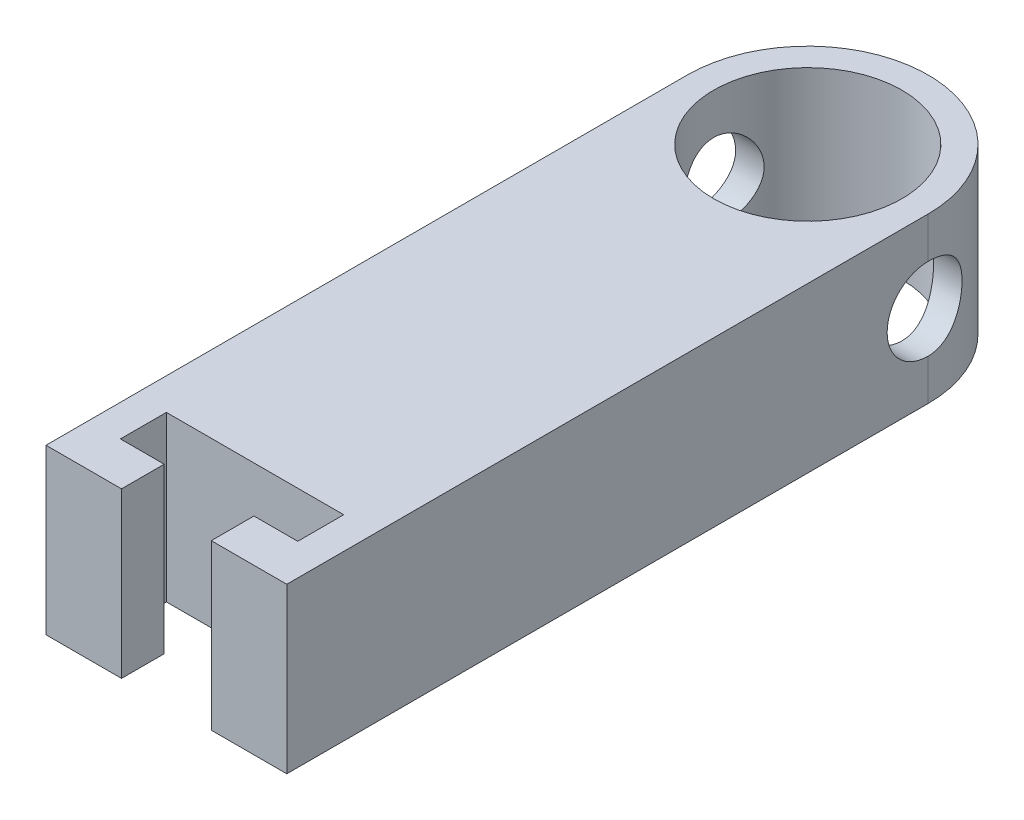
from build123d import *

# Parameters (mm, degrees)
SKETCH2_W               = 20.32
SKETCH2_H               = 7.62
SKETCH2_R               = 1.905
BOSS_EXTRUDE1_DEPTH     = 12.7
BOSS_EXTRUDE1_2_DEPTH   = 12.7
SKETCH4_W               = 7.62
SKETCH4_H               = 55.88
BOSS_EXTRUDE2_DEPTH     = 28.702
SKETCH5_W               = 27.94
SKETCH5_H               = 55.88
BOSS_EXTRUDE3_DEPTH     = 7.62
SKETCH6_R               = 10.922
BOSS_EXTRUDE6_DEPTH     = 55.88
SKETCH7_R               = 4.7625
CUT_EXTRUDE1_DEPTH      = 1
CUT_EXTRUDE1_DEPTH_BACK = 28.94
SKETCH8_W               = 27.94
SKETCH8_H               = 55.88
CUT_EXTRUDE2_DEPTH      = 29.702
CUT_EXTRUDE3_DEPTH      = 36.83
BOSS_EXTRUDE7_DEPTH     = 19.05


with BuildPart() as part:
    # Sketch2 → Boss-Extrude1 (new body)
    with BuildSketch(Plane.XY):
        with Locations((0, 24.13)):
            Rectangle(SKETCH2_W, SKETCH2_H)
        with Locations((4.699, 24.13)):
            Circle(SKETCH2_R, mode=Mode.SUBTRACT)
        with Locations((-4.699, 24.13)):
            Circle(SKETCH2_R, mode=Mode.SUBTRACT)
    extrude(amount=BOSS_EXTRUDE1_DEPTH)



with BuildPart() as body_2:
    # Sketch2 → Boss-Extrude1 2 (new body)
    with BuildSketch(Plane.XY):
        with Locations((0, -24.13)):
            Rectangle(SKETCH2_W, SKETCH2_H)
        with Locations((-4.699, -24.13)):
            Circle(SKETCH2_R, mode=Mode.SUBTRACT)
        with Locations((4.699, -24.13)):
            Circle(SKETCH2_R, mode=Mode.SUBTRACT)
    extrude(amount=BOSS_EXTRUDE1_2_DEPTH)


with BuildPart() as part_1:
    add(part.part)

    add(body_2.part)  # Boss-Extrude2 merges body 2
    # Sketch4 → Boss-Extrude2 (add)
    with BuildSketch(Plane.XY.offset(12.7)):
        with Locations((-13.97, 0)):
            Rectangle(SKETCH4_W, SKETCH4_H)
    extrude(amount=-BOSS_EXTRUDE2_DEPTH)

    # Sketch5 → Boss-Extrude3 (add)
    with BuildSketch(Plane(origin=(0, 0, -16.002), x_dir=(-1, 0, 0), z_dir=(0, 0, -1))):
        with Locations((3.81, 0)):
            Rectangle(SKETCH5_W, SKETCH5_H)
    extrude(amount=BOSS_EXTRUDE3_DEPTH)

    # Sketch6 → Boss-Extrude6 (add)
    with BuildSketch(Plane(origin=(0, 27.94, 0), x_dir=(1, 0, 0), z_dir=(0, 1, 0))):
        with BuildLine():
            Line((4.900385525, 23.622), (10.16, 23.622))
            Line((10.16, 23.622), (10.16, 34.544))
            ThreePointArc((10.16, 34.544), (-3.81, 48.514), (-17.78, 34.544))
            Line((-17.78, 34.544), (-17.78, 23.622))
            Line((-17.78, 23.622), (-12.520385525, 23.622))
            ThreePointArc((-12.520385525, 23.622), (-3.81, 20.574), (4.900385525, 23.622))
        make_face()
        with Locations((-3.81, 34.544)):
            Circle(SKETCH6_R, mode=Mode.SUBTRACT)
    extrude(amount=-BOSS_EXTRUDE6_DEPTH)

    # Sketch7 → Cut-Extrude1 (cut, two sides)
    with BuildSketch(Plane(origin=(10.16, 0, 0), x_dir=(0, 0, -1), z_dir=(1, 0, 0))) as cut_extrude1_sk:
        with Locations((34.544, 18.415)):
            Circle(SKETCH7_R)
    extrude(amount=CUT_EXTRUDE1_DEPTH, mode=Mode.SUBTRACT)
    extrude(cut_extrude1_sk.sketch, amount=-CUT_EXTRUDE1_DEPTH_BACK, mode=Mode.SUBTRACT)

    # Sketch8 → Cut-Extrude2 (cut, through all)
    with BuildSketch(Plane.XY.offset(-16.002)):
        with Locations((-3.81, 0)):
            Rectangle(SKETCH8_W, SKETCH8_H)
    extrude(amount=CUT_EXTRUDE2_DEPTH, mode=Mode.SUBTRACT)

    # Sketch9 → Cut-Extrude3 (cut)
    with BuildSketch(Plane(origin=(0, -27.94, 0), x_dir=(-1, 0, 0), z_dir=(0, -1, 0))):
        with BuildLine():
            Line((-10.16, 16.002), (17.78, 16.002))
            Line((17.78, 16.002), (17.78, 34.544))
            ThreePointArc((17.78, 34.544), (3.81, 48.514), (-10.16, 34.544))
            Line((-10.16, 34.544), (-10.16, 16.002))
        make_face()
    extrude(amount=-CUT_EXTRUDE3_DEPTH, mode=Mode.SUBTRACT)

    # Sketch10 → Boss-Extrude7 (add)
    with BuildSketch(Plane(origin=(0, 27.94, 0), x_dir=(1, 0, 0), z_dir=(0, 1, 0))):
        Polygon((-9.017, -39.878), (-9.017, -34.925), (-14.097, -34.925), (-14.097, -29.591), (6.477, -29.591), (6.477, -34.925), (1.397, -34.925), (1.397, -39.878), (10.16, -39.878), (10.16, 16.002), (-17.78, 16.002), (-17.78, -39.878), align=None)
    extrude(amount=-BOSS_EXTRUDE7_DEPTH)


solid = part_1.part
